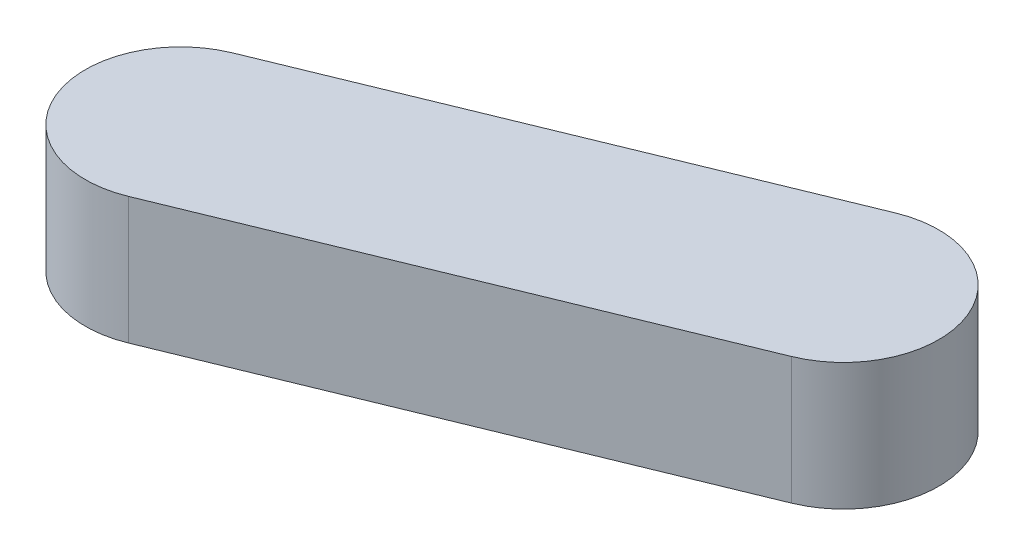
from build123d import *

# Parameters (mm, degrees)
BOSS_EXTRUDE1_DEPTH = 25.4


with BuildPart() as part:
    # Sketch1 → Boss-Extrude1 (new body)
    with BuildSketch(Plane(origin=(0, 0, 0), x_dir=(1, 0, 0), z_dir=(0, 1, 0))):
        with BuildLine():
            Line((-72.113575849, -7.08838816), (21.885374103, 31.470105171))
            ThreePointArc((21.885374103, 31.470105171), (46.739894718, 21.075019555), (36.344809102, -3.779501061))
            Line((36.344809102, -3.779501061), (-57.65414085, -42.337994392))
            ThreePointArc((-57.65414085, -42.337994392), (-82.508661465, -31.942908775), (-72.113575849, -7.08838816))
        make_face()
    extrude(amount=BOSS_EXTRUDE1_DEPTH)


solid = part.part
